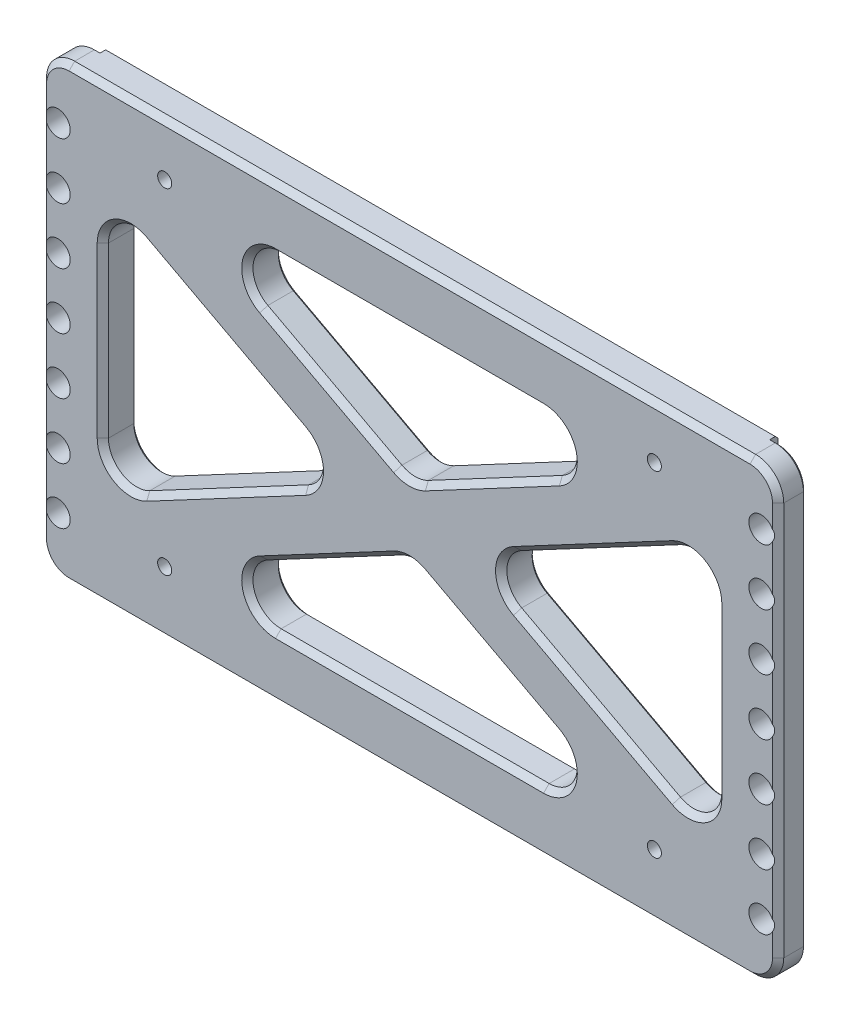
from build123d import *

# Parameters (mm, degrees)
SKETCH_3_W             = 131
SKETCH_3_H             = 80
EXTRUDE_3_DEPTH        = 5
SKETCH_4_W             = 119
SKETCH_4_H             = 80
EXTRUDE_4_DEPTH        = 6
FILLET_2_R             = 5
CHAMFER_1_SIZE         = 1
CUT_EXTRUDE_1_DEPTH    = 6
FILLET_3_R             = 5
CHAMFER_2_SIZE         = 1
SKETCH_6_R             = 2.2
CUT_EXTRUDE_2_DEPTH    = 11
HOLE_WIZARD_M3_1_D     = 2.5
HOLE_WIZARD_M3_1_DEPTH = 7.5
HOLE_WIZARD_M3_1_TIP   = 0.751075774
CHAMFER_3_SIZE         = 0.5


with BuildPart() as part:
    # 草图3 → 凸台-拉伸3 (new body)
    with BuildSketch(Plane.XY):
        with Locations((0, -51.5)):
            Rectangle(SKETCH_3_W, SKETCH_3_H)
    extrude(amount=EXTRUDE_3_DEPTH)

    # 草图4 → 凸台-拉伸4 (add)
    with BuildSketch(Plane.XY.offset(5)):
        with Locations((0, -51.5)):
            Rectangle(SKETCH_4_W, SKETCH_4_H)
    extrude(amount=-EXTRUDE_4_DEPTH)

    # 圆角2
    fillet_2_edges = [part.edges().sort_by_distance(p)[0] for p in [
        (-65.5, -11.5, 2.5),
        (65.5, -11.5, 2.5),
        (65.5, -91.5, 2.5),
        (-65.5, -91.5, 2.5),
    ]]
    fillet(fillet_2_edges, radius=FILLET_2_R)

    # 倒角1
    chamfer_1_edges = [part.edges().sort_by_distance(p)[0] for p in [
        (0, -11.5, 5),
        (65.5, -51.5, 5),
        (0, -91.5, 5),
        (-65.5, -51.5, 5),
        (64.035533906, -90.035533906, 5),
        (-64.035533906, -90.035533906, 5),
        (-64.035533906, -12.964466094, 5),
        (64.035533906, -12.964466094, 5),
    ]]
    chamfer(chamfer_1_edges, length=CHAMFER_1_SIZE)

    # 草图5 → 切除-拉伸1 (cut)
    with BuildSketch(Plane.XY.offset(5)):
        Polygon((-10.644021059, -51.5), (-54.5, -28.163791023), (-54.5, -74.836208978), align=None)
        Polygon((43.855978941, -22.5), (-43.855978941, -22.5), (0, -45.836208978), align=None)
        Polygon((54.5, -28.163791023), (10.644021059, -51.5), (54.5, -74.836208978), align=None)
        Polygon((43.855978941, -80.5), (0, -57.163791023), (-43.855978941, -80.5), align=None)
    extrude(amount=-CUT_EXTRUDE_1_DEPTH, mode=Mode.SUBTRACT)

    # 圆角3
    fillet_3_edges = [part.edges().sort_by_distance(p)[0] for p in [
        (10.644021059, -51.5, 2),
        (54.5, -28.163791023, 2),
        (54.5, -74.836208978, 2),
        (-43.855978941, -22.5, 2),
        (43.855978941, -22.5, 2),
        (0, -45.836208978, 2),
        (-43.855978941, -80.5, 2),
        (0, -57.163791023, 2),
        (43.855978941, -80.5, 2),
        (-54.5, -74.836208978, 2),
        (-54.5, -28.163791023, 2),
        (-10.644021059, -51.5, 2),
    ]]
    fillet(fillet_3_edges, radius=FILLET_3_R)

    # 倒角2
    chamfer_2_edges = [part.edges().sort_by_distance(p)[0] for p in [
        (33.045284631, -39.580061586, 5),
        (54.5, -51.5, 5),
        (33.045284631, -63.419938415, 5),
        (14.256439507, -38.250213644, 5),
        (-14.256439507, -38.250213644, 5),
        (0, -22.5, 5),
        (-33.045284631, -39.580061586, 5),
        (-33.045284631, -63.419938415, 5),
        (-54.5, -51.5, 5),
        (-14.256439507, -64.749786356, 5),
        (14.256439507, -64.749786356, 5),
        (0, -80.5, 5),
        (52.074521107, -32.201893935, 5),
        (52.074521107, -70.798106066, 5),
        (16.288042118, -51.5, 5),
        (0, -45.172417956, 5),
        (-28.666695849, -26.289632976, 5),
        (28.666695849, -26.289632976, 5),
        (-16.288042118, -51.5, 5),
        (-52.074521107, -70.798106066, 5),
        (-52.074521107, -32.201893935, 5),
        (0, -57.827582045, 5),
        (28.666695849, -76.710367025, 5),
        (-28.666695849, -76.710367025, 5),
    ]]
    chamfer(chamfer_2_edges, length=CHAMFER_2_SIZE)

    # 草图6 → 切除-拉伸2 (cut)
    with BuildSketch(Plane.XY.offset(5)):
        with Locations((62.5, -21.5)):
            Circle(SKETCH_6_R)
        with Locations((62.5, -31.5)):
            Circle(SKETCH_6_R)
        with Locations((62.5, -41.5)):
            Circle(SKETCH_6_R)
        with Locations((62.5, -51.5)):
            Circle(SKETCH_6_R)
        with Locations((62.5, -61.5)):
            Circle(SKETCH_6_R)
        with Locations((62.5, -71.5)):
            Circle(SKETCH_6_R)
        with Locations((62.5, -81.5)):
            Circle(SKETCH_6_R)
    cut_extrude_2 = extrude(amount=-CUT_EXTRUDE_2_DEPTH, mode=Mode.SUBTRACT)

    # 镜向1: 切除-拉伸2 across plane
    add(cut_extrude_2.mirror(Plane(origin=(0, 0, 0), x_dir=(0, 0, 1), z_dir=(1, 0, 0))), mode=Mode.SUBTRACT)

    # M3 螺纹孔1
    with Locations(Plane.XY.offset(5)):
        with Locations((-43.51, -20.75), (43.51, -20.75), (43.51, -80.29), (-43.51, -80.29)):
            Hole(HOLE_WIZARD_M3_1_D / 2, depth=HOLE_WIZARD_M3_1_DEPTH)
            with Locations((0, 0, -(HOLE_WIZARD_M3_1_DEPTH + HOLE_WIZARD_M3_1_TIP / 2))):  # 118° drill point
                Cone(0, HOLE_WIZARD_M3_1_D / 2, HOLE_WIZARD_M3_1_TIP, mode=Mode.SUBTRACT)

    # 倒角3
    chamfer_3_edges = [part.edges().sort_by_distance(p)[0] for p in [
        (33.045284631, -39.580061586, -1),
        (54.5, -51.5, -1),
        (33.045284631, -63.419938415, -1),
        (14.256439507, -38.250213644, -1),
        (-60, -11.5, 0),
        (-14.256439507, -38.250213644, -1),
        (0, -22.5, -1),
        (60, -91.5, 0),
        (-33.045284631, -39.580061586, -1),
        (-33.045284631, -63.419938415, -1),
        (-54.5, -51.5, -1),
        (-14.256439507, -64.749786356, -1),
        (14.256439507, -64.749786356, -1),
        (0, -80.5, -1),
        (52.074521107, -32.201893935, -1),
        (52.074521107, -70.798106066, -1),
        (16.288042118, -51.5, -1),
        (0, -45.172417956, -1),
        (-28.666695849, -26.289632976, -1),
        (28.666695849, -26.289632976, -1),
        (-16.288042118, -51.5, -1),
        (-52.074521107, -70.798106066, -1),
        (-52.074521107, -32.201893935, -1),
        (0, -57.827582045, -1),
        (28.666695849, -76.710367025, -1),
        (-28.666695849, -76.710367025, -1),
        (0, -91.5, -1),
        (0, -11.5, -1),
        (60, -11.5, 0),
        (65.5, -51.5, 0),
        (64.035533906, -90.035533906, 0),
        (64.035533906, -12.964466094, 0),
        (-65.5, -51.5, 0),
        (-60, -91.5, 0),
        (-64.035533906, -90.035533906, 0),
        (-64.035533906, -12.964466094, 0),
    ]]
    chamfer(chamfer_3_edges, length=CHAMFER_3_SIZE)


solid = part.part
